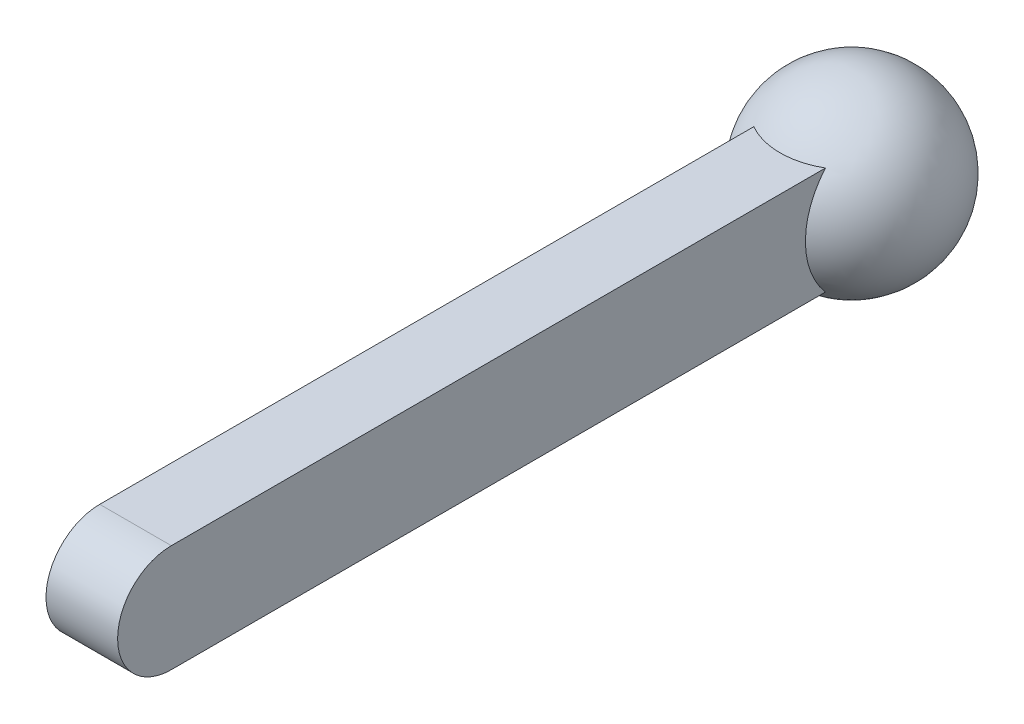
from build123d import *

# Parameters (mm, degrees)
EXTRUDE_1_DEPTH = 10


with BuildPart() as part:
    # 草图1 → 凸台-拉伸1 (new body, symmetric)
    with BuildSketch(Plane(origin=(0, 0, 0), x_dir=(0, 0, -1), z_dir=(1, 0, 0))):
        with BuildLine():
            Line((0, 15), (200, 15))
            ThreePointArc((200, 15), (215, 0), (200, -15))
            Line((200, -15), (0, -15))
            ThreePointArc((0, -15), (-15, 0), (0, 15))
        make_face()
    extrude(amount=EXTRUDE_1_DEPTH, both=True)

    # 草图2 → 旋转1 (revolve)
    with BuildSketch(Plane(origin=(0, 0, 0), x_dir=(0, 0, -1), z_dir=(1, 0, 0))):
        with BuildLine():
            Line((200, 25), (200, -25))
            ThreePointArc((200, -25), (225, 0), (200, 25))
        make_face()
    revolve(axis=Axis((0, 25, -200), (0, -1, 0)))


solid = part.part
